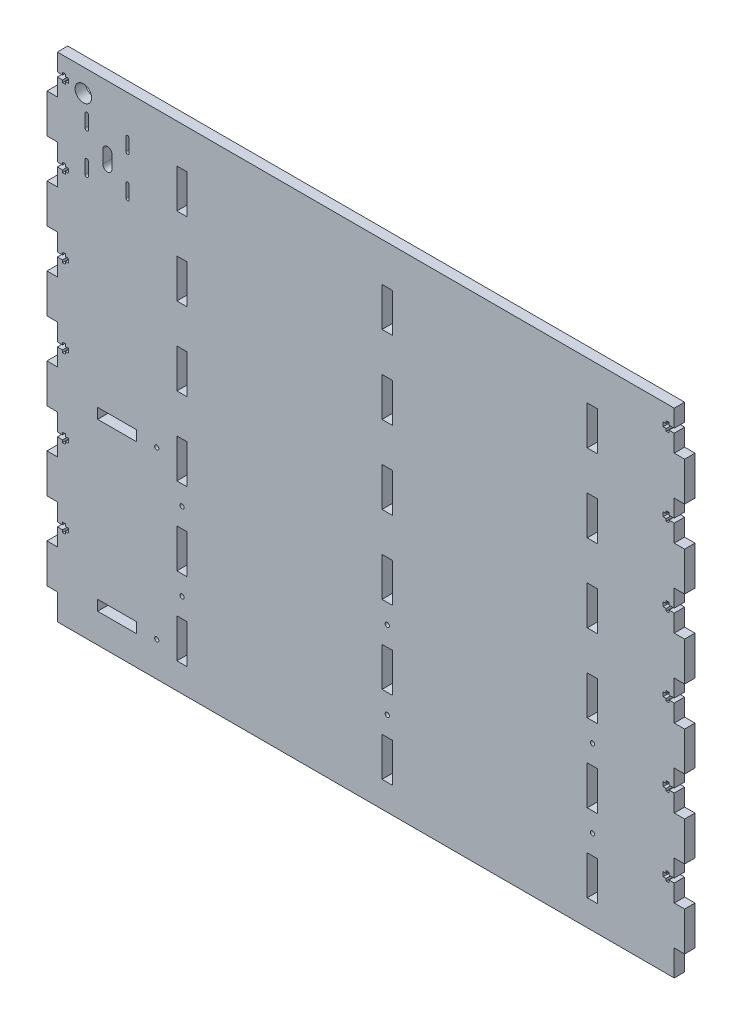
from build123d import *

# Parameters (mm, degrees)
SKETCH1_W           = 475
SKETCH1_H           = 380
SKETCH1_R           = 6.35
SKETCH1_R_2         = 1.65
SKETCH1_W_2         = 30
SKETCH1_H_2         = 8
SKETCH1_W_3         = 8
SKETCH1_H_3         = 30
BOSS_EXTRUDE1_DEPTH = 8
SKETCH2_W           = 8
SKETCH2_H           = 30
BOSS_EXTRUDE2_DEPTH = 8
CUT_EXTRUDE1_DEPTH  = 9


with BuildPart() as part:
    # Sketch1 → Boss-Extrude1 (new body)
    with BuildSketch(Plane.XY):
        with Locations((237.5, 190)):
            Rectangle(SKETCH1_W, SKETCH1_H)
        with Locations((20, 362.5)):
            Circle(SKETCH1_R, mode=Mode.SUBTRACT)
        with Locations((76.5, 154.566938385)):
            Circle(SKETCH1_R_2, mode=Mode.SUBTRACT)
        with Locations((76.5, 26.566938385)):
            Circle(SKETCH1_R_2, mode=Mode.SUBTRACT)
        with Locations((96, 125)):
            Circle(SKETCH1_R_2, mode=Mode.SUBTRACT)
        with Locations((254, 125)):
            Circle(SKETCH1_R_2, mode=Mode.SUBTRACT)
        with Locations((412, 125)):
            Circle(SKETCH1_R_2, mode=Mode.SUBTRACT)
        with Locations((96, 65)):
            Circle(SKETCH1_R_2, mode=Mode.SUBTRACT)
        with Locations((254, 65)):
            Circle(SKETCH1_R_2, mode=Mode.SUBTRACT)
        with Locations((412, 65)):
            Circle(SKETCH1_R_2, mode=Mode.SUBTRACT)
        with BuildLine():
            Line((42.045625982, 332.817349227), (42.045625982, 322.817349227))
            ThreePointArc((42.045625982, 322.817349227), (38.545625982, 319.317349227), (35.045625982, 322.817349227))
            Line((35.045625982, 322.817349227), (35.045625982, 332.817349227))
            ThreePointArc((35.045625982, 332.817349227), (38.545625982, 336.317349227), (42.045625982, 332.817349227))
        make_face(mode=Mode.SUBTRACT)
        with BuildLine():
            Line((55.345625982, 350), (55.345625982, 340))
            ThreePointArc((55.345625982, 340), (54.045625982, 338.7), (52.745625982, 340))
            Line((52.745625982, 340), (52.745625982, 350))
            ThreePointArc((52.745625982, 350), (54.045625982, 351.3), (55.345625982, 350))
        make_face(mode=Mode.SUBTRACT)
        with BuildLine():
            Line((23.944989046, 350), (23.944989046, 340))
            ThreePointArc((23.944989046, 340), (22.644989046, 338.7), (21.344989046, 340))
            Line((21.344989046, 340), (21.344989046, 350))
            ThreePointArc((21.344989046, 350), (22.644989046, 351.3), (23.944989046, 350))
        make_face(mode=Mode.SUBTRACT)
        with BuildLine():
            Line((55.345625982, 319), (55.345625982, 309))
            ThreePointArc((55.345625982, 309), (54.045625982, 307.7), (52.745625982, 309))
            Line((52.745625982, 309), (52.745625982, 319))
            ThreePointArc((52.745625982, 319), (54.045625982, 320.3), (55.345625982, 319))
        make_face(mode=Mode.SUBTRACT)
        with BuildLine():
            Line((23.944989046, 319), (23.944989046, 309))
            ThreePointArc((23.944989046, 309), (22.644989046, 307.7), (21.344989046, 309))
            Line((21.344989046, 309), (21.344989046, 319))
            ThreePointArc((21.344989046, 319), (22.644989046, 320.3), (23.944989046, 319))
        make_face(mode=Mode.SUBTRACT)
        with Locations((46, 26.566938385)):
            Rectangle(SKETCH1_W_2, SKETCH1_H_2, mode=Mode.SUBTRACT)
        with Locations((46, 154.566938385)):
            Rectangle(SKETCH1_W_2, SKETCH1_H_2, mode=Mode.SUBTRACT)
        with Locations((96, 335)):
            Rectangle(SKETCH1_W_3, SKETCH1_H_3, mode=Mode.SUBTRACT)
        with Locations((254, 335)):
            Rectangle(SKETCH1_W_3, SKETCH1_H_3, mode=Mode.SUBTRACT)
        with Locations((412, 335)):
            Rectangle(SKETCH1_W_3, SKETCH1_H_3, mode=Mode.SUBTRACT)
        with Locations((96, 275)):
            Rectangle(SKETCH1_W_3, SKETCH1_H_3, mode=Mode.SUBTRACT)
        with Locations((254, 275)):
            Rectangle(SKETCH1_W_3, SKETCH1_H_3, mode=Mode.SUBTRACT)
        with Locations((412, 275)):
            Rectangle(SKETCH1_W_3, SKETCH1_H_3, mode=Mode.SUBTRACT)
        with Locations((96, 215)):
            Rectangle(SKETCH1_W_3, SKETCH1_H_3, mode=Mode.SUBTRACT)
        with Locations((254, 215)):
            Rectangle(SKETCH1_W_3, SKETCH1_H_3, mode=Mode.SUBTRACT)
        with Locations((412, 215)):
            Rectangle(SKETCH1_W_3, SKETCH1_H_3, mode=Mode.SUBTRACT)
        with Locations((96, 155)):
            Rectangle(SKETCH1_W_3, SKETCH1_H_3, mode=Mode.SUBTRACT)
        with Locations((254, 155)):
            Rectangle(SKETCH1_W_3, SKETCH1_H_3, mode=Mode.SUBTRACT)
        with Locations((412, 155)):
            Rectangle(SKETCH1_W_3, SKETCH1_H_3, mode=Mode.SUBTRACT)
        with Locations((96, 95)):
            Rectangle(SKETCH1_W_3, SKETCH1_H_3, mode=Mode.SUBTRACT)
        with Locations((254, 95)):
            Rectangle(SKETCH1_W_3, SKETCH1_H_3, mode=Mode.SUBTRACT)
        with Locations((412, 95)):
            Rectangle(SKETCH1_W_3, SKETCH1_H_3, mode=Mode.SUBTRACT)
        with Locations((96, 35)):
            Rectangle(SKETCH1_W_3, SKETCH1_H_3, mode=Mode.SUBTRACT)
        with Locations((254, 35)):
            Rectangle(SKETCH1_W_3, SKETCH1_H_3, mode=Mode.SUBTRACT)
        with Locations((412, 35)):
            Rectangle(SKETCH1_W_3, SKETCH1_H_3, mode=Mode.SUBTRACT)
    extrude(amount=BOSS_EXTRUDE1_DEPTH)

    # Sketch2 → Boss-Extrude2 (add)
    with BuildSketch(Plane.XY.offset(8)):
        with Locations((-4, 335)):
            Rectangle(SKETCH2_W, SKETCH2_H)
        with Locations((479, 35)):
            Rectangle(SKETCH2_W, SKETCH2_H)
        with Locations((479, 95)):
            Rectangle(SKETCH2_W, SKETCH2_H)
        with Locations((479, 155)):
            Rectangle(SKETCH2_W, SKETCH2_H)
        with Locations((479, 215)):
            Rectangle(SKETCH2_W, SKETCH2_H)
        with Locations((479, 275)):
            Rectangle(SKETCH2_W, SKETCH2_H)
        with Locations((479, 335)):
            Rectangle(SKETCH2_W, SKETCH2_H)
        with Locations((-4, 275)):
            Rectangle(SKETCH2_W, SKETCH2_H)
        with Locations((-4, 215)):
            Rectangle(SKETCH2_W, SKETCH2_H)
        with Locations((-4, 155)):
            Rectangle(SKETCH2_W, SKETCH2_H)
        with Locations((-4, 95)):
            Rectangle(SKETCH2_W, SKETCH2_H)
        with Locations((-4, 35)):
            Rectangle(SKETCH2_W, SKETCH2_H)
    extrude(amount=-BOSS_EXTRUDE2_DEPTH)

    # Sketch3 → Cut-Extrude1 (cut, through all)
    with BuildSketch(Plane(origin=(0, 0, 0), x_dir=(-1, 0, 0), z_dir=(0, 0, -1))):
        Polygon((0, 366.65), (-4, 366.65), (-4, 368.5), (-6.2, 368.5), (-6.2, 366.65), (-8.5, 366.65), (-8.5, 363.35), (-6.2, 363.35), (-6.2, 361.5), (-4, 361.5), (-4, 363.35), (0, 363.35), align=None)
        Polygon((0, 306.65), (-4, 306.65), (-4, 308.5), (-6.2, 308.5), (-6.2, 306.65), (-8.5, 306.65), (-8.5, 303.35), (-6.2, 303.35), (-6.2, 301.5), (-4, 301.5), (-4, 303.35), (0, 303.35), align=None)
        Polygon((0, 246.65), (-4, 246.65), (-4, 248.5), (-6.2, 248.5), (-6.2, 246.65), (-8.5, 246.65), (-8.5, 243.35), (-6.2, 243.35), (-6.2, 241.5), (-4, 241.5), (-4, 243.35), (0, 243.35), align=None)
        Polygon((0, 186.65), (-4, 186.65), (-4, 188.5), (-6.2, 188.5), (-6.2, 186.65), (-8.5, 186.65), (-8.5, 183.35), (-6.2, 183.35), (-6.2, 181.5), (-4, 181.5), (-4, 183.35), (0, 183.35), align=None)
        Polygon((0, 126.65), (-4, 126.65), (-4, 128.5), (-6.2, 128.5), (-6.2, 126.65), (-8.5, 126.65), (-8.5, 123.35), (-6.2, 123.35), (-6.2, 121.5), (-4, 121.5), (-4, 123.35), (0, 123.35), align=None)
        Polygon((0, 66.65), (-4, 66.65), (-4, 68.5), (-6.2, 68.5), (-6.2, 66.65), (-8.5, 66.65), (-8.5, 63.35), (-6.2, 63.35), (-6.2, 61.5), (-4, 61.5), (-4, 63.35), (0, 63.35), align=None)
        Polygon((-475, 363.35), (-471, 363.35), (-471, 361.5), (-468.8, 361.5), (-468.8, 363.35), (-466.5, 363.35), (-466.5, 366.65), (-468.8, 366.65), (-468.8, 368.5), (-471, 368.5), (-471, 366.65), (-475, 366.65), align=None)
        Polygon((-475, 63.35), (-471, 63.35), (-471, 61.5), (-468.8, 61.5), (-468.8, 63.35), (-466.5, 63.35), (-466.5, 66.65), (-468.8, 66.65), (-468.8, 68.5), (-471, 68.5), (-471, 66.65), (-475, 66.65), align=None)
        Polygon((-475, 123.35), (-471, 123.35), (-471, 121.5), (-468.8, 121.5), (-468.8, 123.35), (-466.5, 123.35), (-466.5, 126.65), (-468.8, 126.65), (-468.8, 128.5), (-471, 128.5), (-471, 126.65), (-475, 126.65), align=None)
        Polygon((-475, 183.35), (-471, 183.35), (-471, 181.5), (-468.8, 181.5), (-468.8, 183.35), (-466.5, 183.35), (-466.5, 186.65), (-468.8, 186.65), (-468.8, 188.5), (-471, 188.5), (-471, 186.65), (-475, 186.65), align=None)
        Polygon((-475, 243.35), (-471, 243.35), (-471, 241.5), (-468.8, 241.5), (-468.8, 243.35), (-466.5, 243.35), (-466.5, 246.65), (-468.8, 246.65), (-468.8, 248.5), (-471, 248.5), (-471, 246.65), (-475, 246.65), align=None)
        Polygon((-475, 303.35), (-471, 303.35), (-471, 301.5), (-468.8, 301.5), (-468.8, 303.35), (-466.5, 303.35), (-466.5, 306.65), (-468.8, 306.65), (-468.8, 308.5), (-471, 308.5), (-471, 306.65), (-475, 306.65), align=None)
    extrude(amount=-CUT_EXTRUDE1_DEPTH, mode=Mode.SUBTRACT)


solid = part.part
